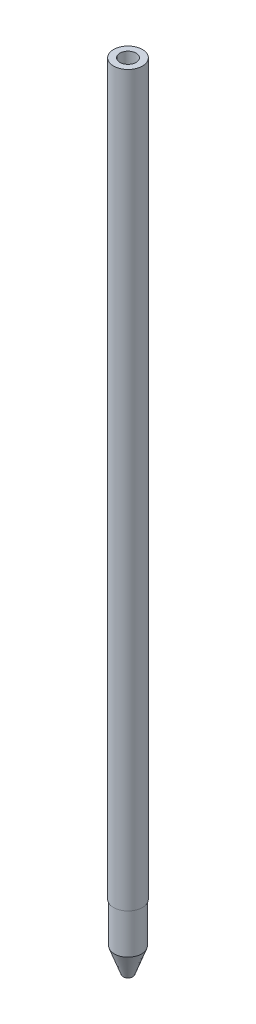
from build123d import *

# Parameters (mm, degrees)
SKETCH2_R           = 1.778
BOSS_EXTRUDE1_DEPTH = 89.9922
SKETCH3_R           = 1.6891
BOSS_EXTRUDE2_DEPTH = 8.001
SKETCH4_R           = 0.99949
CUT_EXTRUDE1_DEPTH  = 86.995
SKETCH5_R           = 1.7526
CUT_EXTRUDE2_DEPTH  = 2.9972


with BuildPart() as part:
    # Sketch2 → Boss-Extrude1 (new body)
    with BuildSketch(Plane(origin=(0, 0, 0), x_dir=(1, 0, 0), z_dir=(0, 1, 0))):
        Circle(SKETCH2_R)
    extrude(amount=BOSS_EXTRUDE1_DEPTH)

    # Sketch3 → Boss-Extrude2 (add)
    with BuildSketch(Plane(origin=(0, 2.9972, 0), x_dir=(1, 0, 0), z_dir=(0, 1, 0))):
        Circle(SKETCH3_R)
    extrude(amount=-BOSS_EXTRUDE2_DEPTH)

    # Sketch4 → Cut-Extrude1 (cut)
    with BuildSketch(Plane(origin=(0, 89.9922, 0), x_dir=(1, 0, 0), z_dir=(0, 1, 0))):
        Circle(SKETCH4_R)
    extrude(amount=-CUT_EXTRUDE1_DEPTH, mode=Mode.SUBTRACT)

    # Sketch5 → Cut-Extrude2 (cut)
    with BuildSketch(Plane(origin=(0, 2.9972, 0), x_dir=(1, 0, 0), z_dir=(0, 1, 0))):
        Circle(SKETCH5_R)
    extrude(amount=-CUT_EXTRUDE2_DEPTH, mode=Mode.SUBTRACT)

    # Sketch6 → Revolve2 (revolve)
    with BuildSketch(Plane.XY):
        Polygon((-1.6891, -5.0038), (-0.598208414, -8.001), (0, -8.001), (0, -5.0038), align=None)
    revolve(axis=Axis((0, 0, 0), (0, -1, 0)))


solid = part.part
